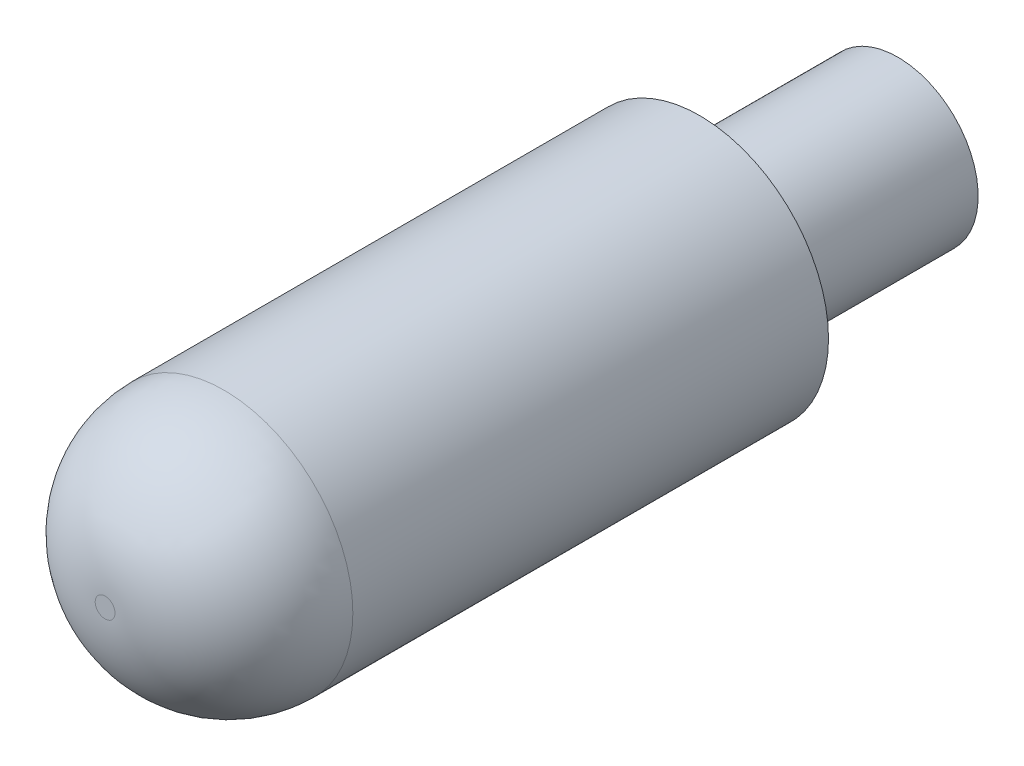
from build123d import *

# Parameters (mm, degrees)
ESQUISSE1_R        = 6.5
BOSS_EXTRU_1_DEPTH = 30
ESQUISSE2_R        = 4.05
BOSS_EXTRU_2_DEPTH = 10
CONG_4_R           = 6


with BuildPart() as part:
    # Esquisse1 → Boss.-Extru.1 (new body)
    with BuildSketch(Plane.XY):
        Circle(ESQUISSE1_R)
    extrude(amount=BOSS_EXTRU_1_DEPTH)

    # Esquisse2 → Boss.-Extru.2 (add)
    with BuildSketch(Plane(origin=(0, 0, 0), x_dir=(-1, 0, 0), z_dir=(0, 0, -1))):
        Circle(ESQUISSE2_R)
    extrude(amount=BOSS_EXTRU_2_DEPTH)

    # Congé4
    cong_4_edges = [part.edges().sort_by_distance(p)[0] for p in [
        (-6.5, 0, 30),
    ]]
    fillet(cong_4_edges, radius=CONG_4_R)


solid = part.part
